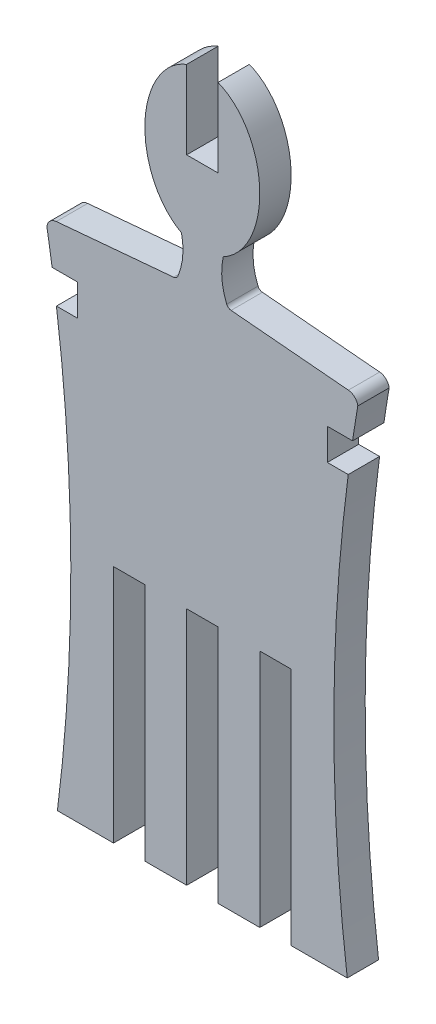
from build123d import *

# Parameters (mm, degrees)
BOSS_EXTRUDE3_DEPTH = 3


with BuildPart() as part:
    # Sketch3 → Boss-Extrude3 (new body)
    with BuildSketch(Plane.XY):
        with BuildLine():
            Line((1.5, -40.798266812), (1.5, -17.877938214))
            Line((1.5, -17.877938214), (-1.5, -17.877938214))
            Line((-1.5, -17.877938214), (-1.5, -40.798266812))
            Line((-1.5, -40.798266812), (-5.5, -40.798266812))
            Line((-5.5, -40.798266812), (-5.5, -17.877938214))
            Line((-5.5, -17.877938214), (-8.5, -17.877938214))
            Line((-8.5, -17.877938214), (-8.5, -40.798266812))
            Line((-8.5, -40.798266812), (-13.869579038, -40.798266812))
            ThreePointArc((-13.869579038, -40.798266812), (-12.587739972, -19.904581661), (-13.963477054, 0.983130949))
            Line((-13.963477054, 0.983130949), (-11.963477054, 0.983130949))
            Line((-11.963477054, 0.983130949), (-11.963477054, 3.983130949))
            Line((-11.963477054, 3.983130949), (-14.381577939, 3.983130949))
            ThreePointArc((-14.381577939, 3.983130949), (-14.622945439, 5.553795951), (-14.879439279, 7.122061786))
            ThreePointArc((-14.879439279, 7.122061786), (-14.579260447, 7.711309245), (-13.976966099, 7.984368613))
            Line((-13.976966099, 7.984368613), (-2.75, 8.982321155))
            ThreePointArc((-2.75, 8.982321155), (-2.498879462, 9.076941447), (-2.33284853, 9.287768993))
            ThreePointArc((-2.33284853, 9.287768993), (-1.875511855, 11.141722585), (-2, 13.047189315))
            add(Edge.make_bspline(
                [(-1.5, 27.249432049), (-17.245966692, 21.162756592), (-2, 13.047189315)],
                knots=[3.417819284, 3.417819284, 3.417819284, 5.911016773, 5.911016773, 5.911016773], degree=2, weights=[1, 0.318548271, 1]))
            Line((-1.5, 27.249432049), (-1.5, 19.749432049))
            Line((-1.5, 19.749432049), (1.5, 19.749432049))
            Line((1.5, 19.749432049), (1.5, 27.249432049))
            add(Edge.make_bspline(
                [(2, 13.047189315), (17.245966692, 21.162756592), (1.5, 27.249432049)],
                knots=[0.372168534, 0.372168534, 0.372168534, 2.865366023, 2.865366023, 2.865366023], degree=2, weights=[1, 0.318548271, 1]))
            ThreePointArc((2, 13.047189315), (1.875511855, 11.141722585), (2.33284853, 9.287768993))
            ThreePointArc((2.33284853, 9.287768993), (2.498879462, 9.076941447), (2.75, 8.982321155))
            Line((2.75, 8.982321155), (13.976966099, 7.984368613))
            ThreePointArc((13.976966099, 7.984368613), (14.579260447, 7.711309245), (14.879439279, 7.122061786))
            ThreePointArc((14.879439279, 7.122061786), (14.622945439, 5.553795951), (14.381577939, 3.983130949))
            Line((14.381577939, 3.983130949), (11.963477054, 3.983130949))
            Line((11.963477054, 3.983130949), (11.963477054, 0.983130949))
            Line((11.963477054, 0.983130949), (13.963477054, 0.983130949))
            ThreePointArc((13.963477054, 0.983130949), (12.587739972, -19.904581661), (13.869579038, -40.798266812))
            Line((13.869579038, -40.798266812), (8.5, -40.798266812))
            Line((8.5, -40.798266812), (8.5, -17.877938214))
            Line((8.5, -17.877938214), (5.5, -17.877938214))
            Line((5.5, -17.877938214), (5.5, -40.798266812))
            Line((5.5, -40.798266812), (1.5, -40.798266812))
        make_face()
    extrude(amount=BOSS_EXTRUDE3_DEPTH)


solid = part.part
